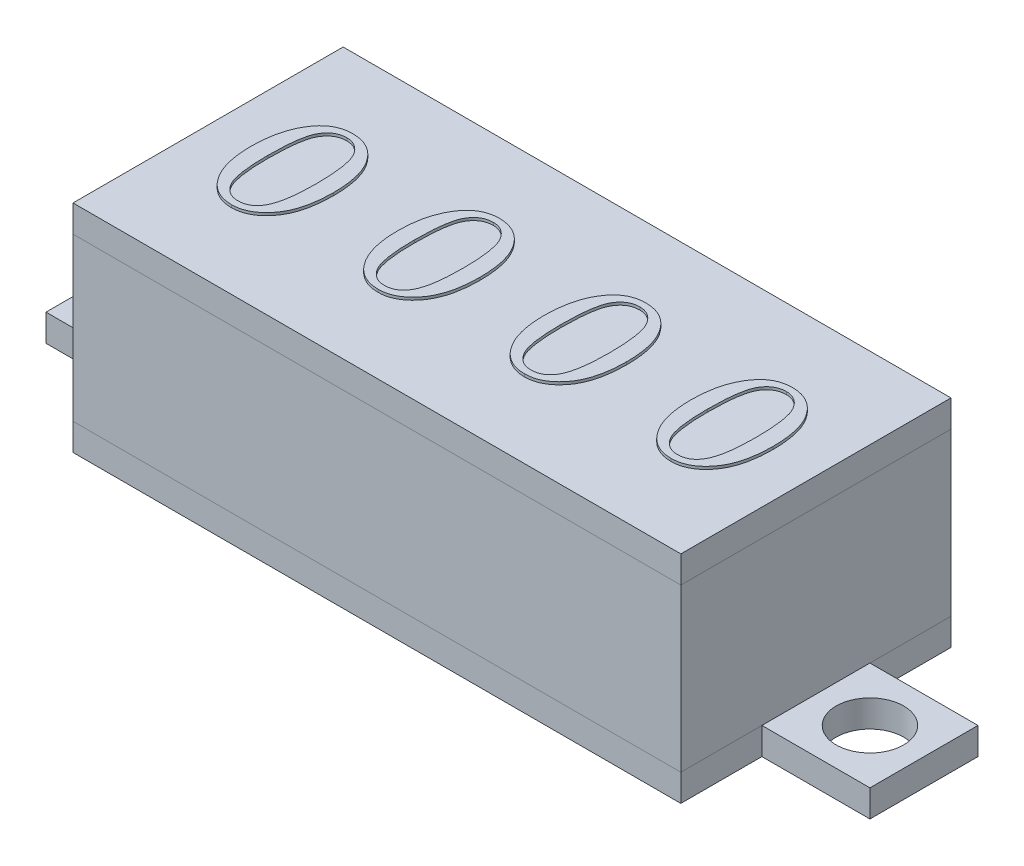
from build123d import *

# Parameters (mm, degrees)
SKETCH1_W           = 22.5
SKETCH1_H           = 10
BOSS_EXTRUDE1_DEPTH = 6
SKETCH2_W           = 4
SKETCH2_H           = 4
SKETCH2_R           = 1.25
BOSS_EXTRUDE2_DEPTH = 1
SKETCH3_W           = 22.5
SKETCH3_H           = 10
BOSS_EXTRUDE3_DEPTH = 1
BOSS_EXTRUDE4_DEPTH = 0.1


with BuildPart() as part:
    # Sketch1 → Boss-Extrude1 (new body)
    with BuildSketch(Plane(origin=(0, 0, 0), x_dir=(1, 0, 0), z_dir=(0, 1, 0))):
        with Locations((-1.188679245, -0.266509434)):
            Rectangle(SKETCH1_W, SKETCH1_H)
    extrude(amount=BOSS_EXTRUDE1_DEPTH)


with BuildPart() as body_2:
    # Sketch2 → Boss-Extrude2 (new body)
    with BuildSketch(Plane.XZ):
        with Locations((12.061320755, 0.266509434)):
            Rectangle(SKETCH2_W, SKETCH2_H)
        with Locations(Location((12.061320755, 0.266509434, 0), (0, 0, 270))):
            Circle(SKETCH2_R, mode=Mode.SUBTRACT)
        Polygon((10.061320755, -4.733490566), (10.061320755, -1.733490566), (10.061320755, 2.266509434), (10.061320755, 5.266509434), (-12.438679245, 5.266509434), (-12.438679245, 2.266509434), (-12.438679245, -1.733490566), (-12.438679245, -4.733490566), align=None)
        with Locations((-14.438679245, 0.266509434)):
            Rectangle(SKETCH2_W, SKETCH2_H)
        with Locations(Location((-14.438679245, 0.266509434, 0), (0, 0, 270))):
            Circle(SKETCH2_R, mode=Mode.SUBTRACT)
    extrude(amount=BOSS_EXTRUDE2_DEPTH)


with BuildPart() as body_3:
    # Sketch3 → Boss-Extrude3 (new body)
    with BuildSketch(Plane(origin=(0, 6, 0), x_dir=(1, 0, 0), z_dir=(0, 1, 0))):
        with Locations((-1.188679245, -0.266509434)):
            Rectangle(SKETCH3_W, SKETCH3_H)
    extrude(amount=BOSS_EXTRUDE3_DEPTH)

    # Sketch4 → Boss-Extrude4 (add)
    with BuildSketch(Plane(origin=(0, 7, 0), x_dir=(1, 0, 0), z_dir=(0, 1, 0))):
        with BuildLine():
            add(Edge.make_bspline(
                [(-9.378258698, 2.032453757), (-9.327945007, 2.031101968), (-9.229301532, 2.028451693), (-9.084815478, 2.004728092), (-8.946425082, 1.968218888), (-8.813834187, 1.916701397), (-8.68887389, 1.847557967), (-8.569923985, 1.765331996), (-8.456275891, 1.669006282), (-8.389049773, 1.594190798), (-8.354734907, 1.55600202)],
                knots=[0, 0, 0, 0, 1.034177873, 2.027577328, 3.003134204, 3.974152387, 4.944805699, 5.933263622, 6.945056114, 8, 8, 8, 8], degree=3))
            add(Edge.make_bspline(
                [(-8.354734907, 1.55600202), (-8.31382028, 1.504857392), (-8.230581065, 1.40080564), (-8.128996208, 1.223059152), (-8.041009839, 1.028343426), (-7.969553671, 0.814433883), (-7.915780217, 0.581591428), (-7.876785917, 0.330148682), (-7.851632366, 0.059989201), (-7.849335115, -0.126586195), (-7.848151835, -0.222688358)],
                knots=[0, 0, 0, 0, 0.831632311, 1.691923517, 2.593854152, 3.545333385, 4.553909998, 5.628531033, 6.778492226, 8, 8, 8, 8], degree=3))
            add(Edge.make_bspline(
                [(-7.848151835, -0.222688358), (-7.849281629, -0.312180841), (-7.851477079, -0.486085272), (-7.872280309, -0.738661839), (-7.907021998, -0.974838883), (-7.954219207, -1.194831114), (-8.016412963, -1.397973632), (-8.091596141, -1.584904206), (-8.181128101, -1.755560206), (-8.284646026, -1.908656843), (-8.397833845, -2.04408024), (-8.51632107, -2.162838309), (-8.641470291, -2.262607987), (-8.77258132, -2.344468194), (-8.909241921, -2.40900764), (-9.052245817, -2.454829643), (-9.200872568, -2.48142185), (-9.301884876, -2.485293605), (-9.352835384, -2.487246514)],
                knots=[0, 0, 0, 0, 1.417208335, 2.753960989, 4.010288699, 5.195991505, 6.314016688, 7.371005355, 8.382792458, 9.360343293, 10.29216761, 11.174475273, 12.012952715, 12.821282545, 13.617429245, 14.400351687, 15.193138972, 16, 16, 16, 16], degree=3))
            add(Edge.make_bspline(
                [(-9.352835384, -2.487246514), (-9.401881597, -2.485821311), (-9.498624784, -2.483010112), (-9.640942977, -2.460001664), (-9.776577486, -2.421166139), (-9.906522268, -2.368241133), (-10.029049142, -2.298465193), (-10.146791862, -2.215418), (-10.257586621, -2.116028725), (-10.323778839, -2.040094149), (-10.35752709, -2.001378735)],
                knots=[0, 0, 0, 0, 1.018622209, 2.009222595, 2.98557584, 3.944681745, 4.91693228, 5.908476626, 6.933632133, 8, 8, 8, 8], degree=3))
            add(Edge.make_bspline(
                [(-10.35752709, -2.001378735), (-10.39796482, -1.948216389), (-10.479896704, -1.840502847), (-10.582423359, -1.660437026), (-10.668839329, -1.464002828), (-10.739375338, -1.250422993), (-10.794616758, -1.020502787), (-10.833713316, -0.773375625), (-10.857456672, -0.509719198), (-10.859985804, -0.328199513), (-10.861285349, -0.234929212)],
                knots=[0, 0, 0, 0, 0.855190123, 1.732721847, 2.647494282, 3.601413261, 4.611082414, 5.674349109, 6.80501028, 8, 8, 8, 8], degree=3))
            add(Edge.make_bspline(
                [(-10.861285349, -0.234929212), (-10.859939267, -0.145737439), (-10.857313641, 0.028237215), (-10.8340092, 0.281995331), (-10.797941251, 0.522150879), (-10.746589341, 0.748339982), (-10.679506042, 0.960640075), (-10.597867472, 1.158754173), (-10.5009474, 1.343149909), (-10.423905088, 1.455929576), (-10.385775216, 1.511746621)],
                knots=[0, 0, 0, 0, 1.162878212, 2.268273489, 3.320083559, 4.327872371, 5.289661935, 6.220038334, 7.119059284, 8, 8, 8, 8], degree=3))
            add(Edge.make_bspline(
                [(-10.385775216, 1.511746621), (-10.353813844, 1.553413836), (-10.291286426, 1.634929216), (-10.182539121, 1.740208345), (-10.068021145, 1.831225702), (-9.944962882, 1.905145925), (-9.813761343, 1.961986842), (-9.675236229, 2.002454193), (-9.529199509, 2.027634542), (-9.429207704, 2.030827065), (-9.378258698, 2.032453757)],
                knots=[0, 0, 0, 0, 1.066527708, 2.08649442, 3.068328227, 4.035911514, 4.996311456, 5.967697152, 6.964477018, 8, 8, 8, 8], degree=3))
        make_face()
        with BuildLine():
            add(Edge.make_bspline(
                [(-9.362251426, 1.791403075), (-9.396529152, 1.790011067), (-9.463676528, 1.787284233), (-9.561853206, 1.769545387), (-9.653624387, 1.737682746), (-9.740621892, 1.695685807), (-9.820200767, 1.638511613), (-9.895103183, 1.570785024), (-9.962847507, 1.489436499), (-10.026828298, 1.395476833), (-10.083427544, 1.281246514), (-10.130418486, 1.142150051), (-10.17000084, 0.977225299), (-10.202054053, 0.786168713), (-10.228576699, 0.56943137), (-10.245112605, 0.32615728), (-10.256875712, 0.056769956), (-10.258046281, -0.131651492), (-10.258658646, -0.230221191)],
                knots=[0, 0, 0, 0, 0.667148774, 1.30689213, 1.932721232, 2.552800968, 3.179791468, 3.832667273, 4.513077547, 5.234758394, 6.04058107, 6.985198211, 8.085901752, 9.338111265, 10.75333435, 12.333478328, 14.081917187, 16, 16, 16, 16], degree=3))
            add(Edge.make_bspline(
                [(-10.258658646, -0.230221191), (-10.257958801, -0.326586914), (-10.256617852, -0.511229992), (-10.245925051, -0.775737788), (-10.225871565, -1.014995372), (-10.200833721, -1.229576412), (-10.16589439, -1.418750484), (-10.125859893, -1.583654584), (-10.07641727, -1.723383545), (-10.018403741, -1.839948095), (-9.95269732, -1.936290582), (-9.884136959, -2.019558757), (-9.808609872, -2.088903785), (-9.728742414, -2.146921369), (-9.643125643, -2.19181073), (-9.552300578, -2.222986474), (-9.456293528, -2.242428337), (-9.390279148, -2.244923117), (-9.3566018, -2.246195833)],
                knots=[0, 0, 0, 0, 1.884102424, 3.610064464, 5.174084282, 6.577654309, 7.831839042, 8.933221405, 9.89214569, 10.723697405, 11.470879788, 12.167811872, 12.827890927, 13.469923399, 14.092994405, 14.710144424, 15.341977984, 16, 16, 16, 16], degree=3))
            add(Edge.make_bspline(
                [(-9.3566018, -2.246195833), (-9.32292856, -2.245253699), (-9.256963501, -2.243408083), (-9.161117903, -2.224692504), (-9.071063216, -2.1957724), (-8.9869214, -2.15473025), (-8.909343422, -2.101600569), (-8.838328527, -2.036521993), (-8.772356363, -1.960677737), (-8.735370795, -1.903028888), (-8.716310929, -1.87332056)],
                knots=[0, 0, 0, 0, 1.037540769, 2.032517106, 2.999982528, 3.948219519, 4.909561987, 5.889684619, 6.91248581, 8, 8, 8, 8], degree=3))
            add(Edge.make_bspline(
                [(-8.716310929, -1.87332056), (-8.694577417, -1.832982896), (-8.648365149, -1.74721236), (-8.596566318, -1.600008061), (-8.550607716, -1.431387215), (-8.513377116, -1.239704893), (-8.48607819, -1.02513749), (-8.465882729, -0.787956682), (-8.452158803, -0.52761392), (-8.451251549, -0.346371551), (-8.450778538, -0.251878088)],
                knots=[0, 0, 0, 0, 0.662021917, 1.407666401, 2.250371803, 3.189876895, 4.229599255, 5.378231133, 6.633100965, 8, 8, 8, 8], degree=3))
            add(Edge.make_bspline(
                [(-8.450778538, -0.251878088), (-8.451302093, -0.154561109), (-8.452304066, 0.031683138), (-8.465277516, 0.298561732), (-8.48286837, 0.540236041), (-8.509624526, 0.756914524), (-8.545521026, 0.948250324), (-8.586226799, 1.115429661), (-8.636785672, 1.257308046), (-8.695764485, 1.375703343), (-8.762318342, 1.474020603), (-8.832257707, 1.558975759), (-8.907352014, 1.631088409), (-8.988673696, 1.689468841), (-9.074945627, 1.734832614), (-9.165901432, 1.768544039), (-9.262599914, 1.78751693), (-9.328587663, 1.790090278), (-9.362251426, 1.791403075)],
                knots=[0, 0, 0, 0, 1.880898734, 3.599644876, 5.163555013, 6.563973479, 7.81694835, 8.92495287, 9.886457661, 10.722129126, 11.474279202, 12.176496217, 12.845948905, 13.480688063, 14.104872593, 14.724796833, 15.349452935, 16, 16, 16, 16], degree=3))
        make_face(mode=Mode.SUBTRACT)
        with BuildLine():
            add(Edge.make_bspline(
                [(-3.954618373, 2.032453757), (-3.904304682, 2.031101968), (-3.805661208, 2.028451693), (-3.661175153, 2.004728092), (-3.522784757, 1.968218888), (-3.390193862, 1.916701397), (-3.265233565, 1.847557967), (-3.14628366, 1.765331996), (-3.032635566, 1.669006282), (-2.965409449, 1.594190798), (-2.931094583, 1.55600202)],
                knots=[0, 0, 0, 0, 1.034177873, 2.027577328, 3.003134204, 3.974152387, 4.944805699, 5.933263622, 6.945056114, 8, 8, 8, 8], degree=3))
            add(Edge.make_bspline(
                [(-2.931094583, 1.55600202), (-2.890179955, 1.504857392), (-2.80694074, 1.40080564), (-2.705355884, 1.223059152), (-2.617369514, 1.028343426), (-2.545913346, 0.814433883), (-2.492139892, 0.581591428), (-2.453145593, 0.330148682), (-2.427992042, 0.059989201), (-2.42569479, -0.126586195), (-2.424511511, -0.222688358)],
                knots=[0, 0, 0, 0, 0.831632311, 1.691923517, 2.593854152, 3.545333385, 4.553909998, 5.628531033, 6.778492226, 8, 8, 8, 8], degree=3))
            add(Edge.make_bspline(
                [(-2.424511511, -0.222688358), (-2.425641305, -0.312180841), (-2.427836754, -0.486085272), (-2.448639984, -0.738661839), (-2.483381673, -0.974838883), (-2.530578882, -1.194831114), (-2.592772638, -1.397973632), (-2.667955816, -1.584904206), (-2.757487776, -1.755560206), (-2.861005701, -1.908656843), (-2.974193521, -2.04408024), (-3.092680746, -2.162838309), (-3.217829967, -2.262607987), (-3.348940996, -2.344468194), (-3.485601596, -2.40900764), (-3.628605493, -2.454829643), (-3.777232244, -2.48142185), (-3.878244551, -2.485293605), (-3.929195059, -2.487246514)],
                knots=[0, 0, 0, 0, 1.417208335, 2.753960989, 4.010288699, 5.195991505, 6.314016688, 7.371005355, 8.382792458, 9.360343293, 10.29216761, 11.174475273, 12.012952715, 12.821282545, 13.617429245, 14.400351687, 15.193138972, 16, 16, 16, 16], degree=3))
            add(Edge.make_bspline(
                [(-3.929195059, -2.487246514), (-3.978241272, -2.485821311), (-4.07498446, -2.483010112), (-4.217302653, -2.460001664), (-4.352937161, -2.421166139), (-4.482881943, -2.368241133), (-4.605408817, -2.298465193), (-4.723151537, -2.215418), (-4.833946296, -2.116028725), (-4.900138515, -2.040094149), (-4.933886765, -2.001378735)],
                knots=[0, 0, 0, 0, 1.018622209, 2.009222595, 2.98557584, 3.944681745, 4.91693228, 5.908476626, 6.933632133, 8, 8, 8, 8], degree=3))
            add(Edge.make_bspline(
                [(-4.933886765, -2.001378735), (-4.974324495, -1.948216389), (-5.05625638, -1.840502847), (-5.158783035, -1.660437026), (-5.245199005, -1.464002828), (-5.315735013, -1.250422993), (-5.370976434, -1.020502787), (-5.410072992, -0.773375625), (-5.433816348, -0.509719198), (-5.43634548, -0.328199513), (-5.437645024, -0.234929212)],
                knots=[0, 0, 0, 0, 0.855190123, 1.732721847, 2.647494282, 3.601413261, 4.611082414, 5.674349109, 6.80501028, 8, 8, 8, 8], degree=3))
            add(Edge.make_bspline(
                [(-5.437645024, -0.234929212), (-5.436298942, -0.145737439), (-5.433673317, 0.028237215), (-5.410368876, 0.281995331), (-5.374300926, 0.522150879), (-5.322949016, 0.748339982), (-5.255865718, 0.960640075), (-5.174227148, 1.158754173), (-5.077307075, 1.343149909), (-5.000264763, 1.455929576), (-4.962134892, 1.511746621)],
                knots=[0, 0, 0, 0, 1.162878212, 2.268273489, 3.320083559, 4.327872371, 5.289661935, 6.220038334, 7.119059284, 8, 8, 8, 8], degree=3))
            add(Edge.make_bspline(
                [(-4.962134892, 1.511746621), (-4.93017352, 1.553413836), (-4.867646101, 1.634929216), (-4.758898797, 1.740208345), (-4.644380821, 1.831225702), (-4.521322557, 1.905145925), (-4.390121019, 1.961986842), (-4.251595904, 2.002454193), (-4.105559185, 2.027634542), (-4.00556738, 2.030827065), (-3.954618373, 2.032453757)],
                knots=[0, 0, 0, 0, 1.066527708, 2.08649442, 3.068328227, 4.035911514, 4.996311456, 5.967697152, 6.964477018, 8, 8, 8, 8], degree=3))
        make_face()
        with BuildLine():
            add(Edge.make_bspline(
                [(-3.938611101, 1.791403075), (-3.972888827, 1.790011067), (-4.040036204, 1.787284233), (-4.138212882, 1.769545387), (-4.229984062, 1.737682746), (-4.316981567, 1.695685807), (-4.396560442, 1.638511613), (-4.471462859, 1.570785024), (-4.539207183, 1.489436499), (-4.603187974, 1.395476833), (-4.65978722, 1.281246514), (-4.706778162, 1.142150051), (-4.746360515, 0.977225299), (-4.778413728, 0.786168713), (-4.804936374, 0.56943137), (-4.82147228, 0.32615728), (-4.833235388, 0.056769956), (-4.834405957, -0.131651492), (-4.835018322, -0.230221191)],
                knots=[0, 0, 0, 0, 0.667148774, 1.30689213, 1.932721232, 2.552800968, 3.179791468, 3.832667273, 4.513077547, 5.234758394, 6.04058107, 6.985198211, 8.085901752, 9.338111265, 10.75333435, 12.333478328, 14.081917187, 16, 16, 16, 16], degree=3))
            add(Edge.make_bspline(
                [(-4.835018322, -0.230221191), (-4.834318476, -0.326586914), (-4.832977527, -0.511229992), (-4.822284726, -0.775737788), (-4.80223124, -1.014995372), (-4.777193396, -1.229576412), (-4.742254066, -1.418750484), (-4.702219569, -1.583654584), (-4.652776946, -1.723383545), (-4.594763416, -1.839948095), (-4.529056995, -1.936290582), (-4.460496635, -2.019558757), (-4.384969547, -2.088903785), (-4.305102089, -2.146921369), (-4.219485318, -2.19181073), (-4.128660254, -2.222986474), (-4.032653204, -2.242428337), (-3.966638824, -2.244923117), (-3.932961476, -2.246195833)],
                knots=[0, 0, 0, 0, 1.884102424, 3.610064464, 5.174084282, 6.577654309, 7.831839042, 8.933221405, 9.89214569, 10.723697405, 11.470879788, 12.167811872, 12.827890927, 13.469923399, 14.092994405, 14.710144424, 15.341977984, 16, 16, 16, 16], degree=3))
            add(Edge.make_bspline(
                [(-3.932961476, -2.246195833), (-3.899288235, -2.245253699), (-3.833323177, -2.243408083), (-3.737477578, -2.224692504), (-3.647422892, -2.1957724), (-3.563281076, -2.15473025), (-3.485703097, -2.101600569), (-3.414688202, -2.036521993), (-3.348716038, -1.960677737), (-3.311730471, -1.903028888), (-3.292670604, -1.87332056)],
                knots=[0, 0, 0, 0, 1.037540769, 2.032517106, 2.999982528, 3.948219519, 4.909561987, 5.889684619, 6.91248581, 8, 8, 8, 8], degree=3))
            add(Edge.make_bspline(
                [(-3.292670604, -1.87332056), (-3.270937093, -1.832982896), (-3.224724825, -1.74721236), (-3.172925993, -1.600008061), (-3.126967392, -1.431387215), (-3.089736791, -1.239704893), (-3.062437865, -1.02513749), (-3.042242404, -0.787956682), (-3.028518478, -0.52761392), (-3.027611224, -0.346371551), (-3.027138213, -0.251878088)],
                knots=[0, 0, 0, 0, 0.662021917, 1.407666401, 2.250371803, 3.189876895, 4.229599255, 5.378231133, 6.633100965, 8, 8, 8, 8], degree=3))
            add(Edge.make_bspline(
                [(-3.027138213, -0.251878088), (-3.027661768, -0.154561109), (-3.028663741, 0.031683138), (-3.041637191, 0.298561732), (-3.059228046, 0.540236041), (-3.085984201, 0.756914524), (-3.121880702, 0.948250324), (-3.162586475, 1.115429661), (-3.213145348, 1.257308046), (-3.272124161, 1.375703343), (-3.338678017, 1.474020603), (-3.408617382, 1.558975759), (-3.48371169, 1.631088409), (-3.565033371, 1.689468841), (-3.651305303, 1.734832614), (-3.742261108, 1.768544039), (-3.83895959, 1.78751693), (-3.904947339, 1.790090278), (-3.938611101, 1.791403075)],
                knots=[0, 0, 0, 0, 1.880898734, 3.599644876, 5.163555013, 6.563973479, 7.81694835, 8.92495287, 9.886457661, 10.722129126, 11.474279202, 12.176496217, 12.845948905, 13.480688063, 14.104872593, 14.724796833, 15.349452935, 16, 16, 16, 16], degree=3))
        make_face(mode=Mode.SUBTRACT)
        with BuildLine():
            add(Edge.make_bspline(
                [(1.469021951, 2.032453757), (1.519335642, 2.031101968), (1.617979117, 2.028451693), (1.762465171, 2.004728092), (1.900855568, 1.968218888), (2.033446462, 1.916701397), (2.158406759, 1.847557967), (2.277356664, 1.765331996), (2.391004758, 1.669006282), (2.458230876, 1.594190798), (2.492545742, 1.55600202)],
                knots=[0, 0, 0, 0, 1.034177873, 2.027577328, 3.003134204, 3.974152387, 4.944805699, 5.933263622, 6.945056114, 8, 8, 8, 8], degree=3))
            add(Edge.make_bspline(
                [(2.492545742, 1.55600202), (2.533460369, 1.504857392), (2.616699584, 1.40080564), (2.718284441, 1.223059152), (2.80627081, 1.028343426), (2.877726978, 0.814433883), (2.931500432, 0.581591428), (2.970494732, 0.330148682), (2.995648283, 0.059989201), (2.997945534, -0.126586195), (2.999128814, -0.222688358)],
                knots=[0, 0, 0, 0, 0.831632311, 1.691923517, 2.593854152, 3.545333385, 4.553909998, 5.628531033, 6.778492226, 8, 8, 8, 8], degree=3))
            add(Edge.make_bspline(
                [(2.999128814, -0.222688358), (2.99799902, -0.312180841), (2.99580357, -0.486085272), (2.97500034, -0.738661839), (2.940258651, -0.974838883), (2.893061442, -1.194831114), (2.830867686, -1.397973632), (2.755684508, -1.584904206), (2.666152548, -1.755560206), (2.562634623, -1.908656843), (2.449446804, -2.04408024), (2.330959579, -2.162838309), (2.205810358, -2.262607987), (2.074699329, -2.344468194), (1.938038728, -2.40900764), (1.795034832, -2.454829643), (1.646408081, -2.48142185), (1.545395774, -2.485293605), (1.494445265, -2.487246514)],
                knots=[0, 0, 0, 0, 1.417208335, 2.753960989, 4.010288699, 5.195991505, 6.314016688, 7.371005355, 8.382792458, 9.360343293, 10.29216761, 11.174475273, 12.012952715, 12.821282545, 13.617429245, 14.400351687, 15.193138972, 16, 16, 16, 16], degree=3))
            add(Edge.make_bspline(
                [(1.494445265, -2.487246514), (1.445399052, -2.485821311), (1.348655865, -2.483010112), (1.206337672, -2.460001664), (1.070703163, -2.421166139), (0.940758381, -2.368241133), (0.818231507, -2.298465193), (0.700488787, -2.215418), (0.589694028, -2.116028725), (0.52350181, -2.040094149), (0.48975356, -2.001378735)],
                knots=[0, 0, 0, 0, 1.018622209, 2.009222595, 2.98557584, 3.944681745, 4.91693228, 5.908476626, 6.933632133, 8, 8, 8, 8], degree=3))
            add(Edge.make_bspline(
                [(0.48975356, -2.001378735), (0.449315829, -1.948216389), (0.367383945, -1.840502847), (0.26485729, -1.660437026), (0.17844132, -1.464002828), (0.107905311, -1.250422993), (0.052663891, -1.020502787), (0.013567333, -0.773375625), (-0.010176023, -0.509719198), (-0.012705155, -0.328199513), (-0.0140047, -0.234929212)],
                knots=[0, 0, 0, 0, 0.855190123, 1.732721847, 2.647494282, 3.601413261, 4.611082414, 5.674349109, 6.80501028, 8, 8, 8, 8], degree=3))
            add(Edge.make_bspline(
                [(-0.0140047, -0.234929212), (-0.012658618, -0.145737439), (-0.010032992, 0.028237215), (0.013271449, 0.281995331), (0.049339399, 0.522150879), (0.100691308, 0.748339982), (0.167774607, 0.960640075), (0.249413177, 1.158754173), (0.346333249, 1.343149909), (0.423375561, 1.455929576), (0.461505433, 1.511746621)],
                knots=[0, 0, 0, 0, 1.162878212, 2.268273489, 3.320083559, 4.327872371, 5.289661935, 6.220038334, 7.119059284, 8, 8, 8, 8], degree=3))
            add(Edge.make_bspline(
                [(0.461505433, 1.511746621), (0.493466805, 1.553413836), (0.555994223, 1.634929216), (0.664741528, 1.740208345), (0.779259504, 1.831225702), (0.902317767, 1.905145925), (1.033519306, 1.961986842), (1.17204442, 2.002454193), (1.31808114, 2.027634542), (1.418072945, 2.030827065), (1.469021951, 2.032453757)],
                knots=[0, 0, 0, 0, 1.066527708, 2.08649442, 3.068328227, 4.035911514, 4.996311456, 5.967697152, 6.964477018, 8, 8, 8, 8], degree=3))
        make_face()
        with BuildLine():
            add(Edge.make_bspline(
                [(1.485029223, 1.791403075), (1.450751497, 1.790011067), (1.383604121, 1.787284233), (1.285427443, 1.769545387), (1.193656262, 1.737682746), (1.106658757, 1.695685807), (1.027079882, 1.638511613), (0.952177466, 1.570785024), (0.884433142, 1.489436499), (0.820452351, 1.395476833), (0.763853105, 1.281246514), (0.716862163, 1.142150051), (0.677279809, 0.977225299), (0.645226597, 0.786168713), (0.61870395, 0.56943137), (0.602168044, 0.32615728), (0.590404937, 0.056769956), (0.589234368, -0.131651492), (0.588622003, -0.230221191)],
                knots=[0, 0, 0, 0, 0.667148774, 1.30689213, 1.932721232, 2.552800968, 3.179791468, 3.832667273, 4.513077547, 5.234758394, 6.04058107, 6.985198211, 8.085901752, 9.338111265, 10.75333435, 12.333478328, 14.081917187, 16, 16, 16, 16], degree=3))
            add(Edge.make_bspline(
                [(0.588622003, -0.230221191), (0.589321848, -0.326586914), (0.590662797, -0.511229992), (0.601355598, -0.775737788), (0.621409084, -1.014995372), (0.646446928, -1.229576412), (0.681386259, -1.418750484), (0.721420756, -1.583654584), (0.770863379, -1.723383545), (0.828876908, -1.839948095), (0.894583329, -1.936290582), (0.96314369, -2.019558757), (1.038670777, -2.088903785), (1.118538235, -2.146921369), (1.204155006, -2.19181073), (1.294980071, -2.222986474), (1.390987121, -2.242428337), (1.457001501, -2.244923117), (1.490678849, -2.246195833)],
                knots=[0, 0, 0, 0, 1.884102424, 3.610064464, 5.174084282, 6.577654309, 7.831839042, 8.933221405, 9.89214569, 10.723697405, 11.470879788, 12.167811872, 12.827890927, 13.469923399, 14.092994405, 14.710144424, 15.341977984, 16, 16, 16, 16], degree=3))
            add(Edge.make_bspline(
                [(1.490678849, -2.246195833), (1.524352089, -2.245253699), (1.590317148, -2.243408083), (1.686162746, -2.224692504), (1.776217433, -2.1957724), (1.860359249, -2.15473025), (1.937937228, -2.101600569), (2.008952122, -2.036521993), (2.074924286, -1.960677737), (2.111909854, -1.903028888), (2.13096972, -1.87332056)],
                knots=[0, 0, 0, 0, 1.037540769, 2.032517106, 2.999982528, 3.948219519, 4.909561987, 5.889684619, 6.91248581, 8, 8, 8, 8], degree=3))
            add(Edge.make_bspline(
                [(2.13096972, -1.87332056), (2.152703232, -1.832982896), (2.1989155, -1.74721236), (2.250714331, -1.600008061), (2.296672933, -1.431387215), (2.333903533, -1.239704893), (2.361202459, -1.02513749), (2.38139792, -0.787956682), (2.395121846, -0.52761392), (2.3960291, -0.346371551), (2.396502111, -0.251878088)],
                knots=[0, 0, 0, 0, 0.662021917, 1.407666401, 2.250371803, 3.189876895, 4.229599255, 5.378231133, 6.633100965, 8, 8, 8, 8], degree=3))
            add(Edge.make_bspline(
                [(2.396502111, -0.251878088), (2.395978557, -0.154561109), (2.394976583, 0.031683138), (2.382003133, 0.298561732), (2.364412279, 0.540236041), (2.337656123, 0.756914524), (2.301759623, 0.948250324), (2.26105385, 1.115429661), (2.210494977, 1.257308046), (2.151516164, 1.375703343), (2.084962307, 1.474020603), (2.015022942, 1.558975759), (1.939928635, 1.631088409), (1.858606953, 1.689468841), (1.772335022, 1.734832614), (1.681379217, 1.768544039), (1.584680735, 1.78751693), (1.518692986, 1.790090278), (1.485029223, 1.791403075)],
                knots=[0, 0, 0, 0, 1.880898734, 3.599644876, 5.163555013, 6.563973479, 7.81694835, 8.92495287, 9.886457661, 10.722129126, 11.474279202, 12.176496217, 12.845948905, 13.480688063, 14.104872593, 14.724796833, 15.349452935, 16, 16, 16, 16], degree=3))
        make_face(mode=Mode.SUBTRACT)
        with BuildLine():
            add(Edge.make_bspline(
                [(6.892662276, 2.032453757), (6.942975967, 2.031101968), (7.041619441, 2.028451693), (7.186105496, 2.004728092), (7.324495892, 1.968218888), (7.457086787, 1.916701397), (7.582047084, 1.847557967), (7.700996989, 1.765331996), (7.814645083, 1.669006282), (7.881871201, 1.594190798), (7.916186066, 1.55600202)],
                knots=[0, 0, 0, 0, 1.034177873, 2.027577328, 3.003134204, 3.974152387, 4.944805699, 5.933263622, 6.945056114, 8, 8, 8, 8], degree=3))
            add(Edge.make_bspline(
                [(7.916186066, 1.55600202), (7.957100694, 1.504857392), (8.040339909, 1.40080564), (8.141924765, 1.223059152), (8.229911135, 1.028343426), (8.301367303, 0.814433883), (8.355140757, 0.581591428), (8.394135057, 0.330148682), (8.419288607, 0.059989201), (8.421585859, -0.126586195), (8.422769138, -0.222688358)],
                knots=[0, 0, 0, 0, 0.831632311, 1.691923517, 2.593854152, 3.545333385, 4.553909998, 5.628531033, 6.778492226, 8, 8, 8, 8], degree=3))
            add(Edge.make_bspline(
                [(8.422769138, -0.222688358), (8.421639344, -0.312180841), (8.419443895, -0.486085272), (8.398640665, -0.738661839), (8.363898976, -0.974838883), (8.316701767, -1.194831114), (8.254508011, -1.397973632), (8.179324833, -1.584904206), (8.089792873, -1.755560206), (7.986274948, -1.908656843), (7.873087128, -2.04408024), (7.754599903, -2.162838309), (7.629450682, -2.262607987), (7.498339654, -2.344468194), (7.361679053, -2.40900764), (7.218675156, -2.454829643), (7.070048405, -2.48142185), (6.969036098, -2.485293605), (6.91808559, -2.487246514)],
                knots=[0, 0, 0, 0, 1.417208335, 2.753960989, 4.010288699, 5.195991505, 6.314016688, 7.371005355, 8.382792458, 9.360343293, 10.29216761, 11.174475273, 12.012952715, 12.821282545, 13.617429245, 14.400351687, 15.193138972, 16, 16, 16, 16], degree=3))
            add(Edge.make_bspline(
                [(6.91808559, -2.487246514), (6.869039377, -2.485821311), (6.772296189, -2.483010112), (6.629977996, -2.460001664), (6.494343488, -2.421166139), (6.364398706, -2.368241133), (6.241871832, -2.298465193), (6.124129112, -2.215418), (6.013334353, -2.116028725), (5.947142135, -2.040094149), (5.913393884, -2.001378735)],
                knots=[0, 0, 0, 0, 1.018622209, 2.009222595, 2.98557584, 3.944681745, 4.91693228, 5.908476626, 6.933632133, 8, 8, 8, 8], degree=3))
            add(Edge.make_bspline(
                [(5.913393884, -2.001378735), (5.872956154, -1.948216389), (5.791024269, -1.840502847), (5.688497615, -1.660437026), (5.602081644, -1.464002828), (5.531545636, -1.250422993), (5.476304215, -1.020502787), (5.437207657, -0.773375625), (5.413464301, -0.509719198), (5.410935169, -0.328199513), (5.409635625, -0.234929212)],
                knots=[0, 0, 0, 0, 0.855190123, 1.732721847, 2.647494282, 3.601413261, 4.611082414, 5.674349109, 6.80501028, 8, 8, 8, 8], degree=3))
            add(Edge.make_bspline(
                [(5.409635625, -0.234929212), (5.410981707, -0.145737439), (5.413607332, 0.028237215), (5.436911773, 0.281995331), (5.472979723, 0.522150879), (5.524331633, 0.748339982), (5.591414931, 0.960640075), (5.673053501, 1.158754173), (5.769973574, 1.343149909), (5.847015886, 1.455929576), (5.885145757, 1.511746621)],
                knots=[0, 0, 0, 0, 1.162878212, 2.268273489, 3.320083559, 4.327872371, 5.289661935, 6.220038334, 7.119059284, 8, 8, 8, 8], degree=3))
            add(Edge.make_bspline(
                [(5.885145757, 1.511746621), (5.917107129, 1.553413836), (5.979634548, 1.634929216), (6.088381852, 1.740208345), (6.202899828, 1.831225702), (6.325958092, 1.905145925), (6.45715963, 1.961986842), (6.595684745, 2.002454193), (6.741721464, 2.027634542), (6.841713269, 2.030827065), (6.892662276, 2.032453757)],
                knots=[0, 0, 0, 0, 1.066527708, 2.08649442, 3.068328227, 4.035911514, 4.996311456, 5.967697152, 6.964477018, 8, 8, 8, 8], degree=3))
        make_face()
        with BuildLine():
            add(Edge.make_bspline(
                [(6.908669548, 1.791403075), (6.874391822, 1.790011067), (6.807244445, 1.787284233), (6.709067767, 1.769545387), (6.617296587, 1.737682746), (6.530299082, 1.695685807), (6.450720207, 1.638511613), (6.37581779, 1.570785024), (6.308073466, 1.489436499), (6.244092675, 1.395476833), (6.187493429, 1.281246514), (6.140502487, 1.142150051), (6.100920134, 0.977225299), (6.068866921, 0.786168713), (6.042344275, 0.56943137), (6.025808369, 0.32615728), (6.014045261, 0.056769956), (6.012874692, -0.131651492), (6.012262327, -0.230221191)],
                knots=[0, 0, 0, 0, 0.667148774, 1.30689213, 1.932721232, 2.552800968, 3.179791468, 3.832667273, 4.513077547, 5.234758394, 6.04058107, 6.985198211, 8.085901752, 9.338111265, 10.75333435, 12.333478328, 14.081917187, 16, 16, 16, 16], degree=3))
            add(Edge.make_bspline(
                [(6.012262327, -0.230221191), (6.012962173, -0.326586914), (6.014303122, -0.511229992), (6.024995923, -0.775737788), (6.045049409, -1.014995372), (6.070087253, -1.229576412), (6.105026583, -1.418750484), (6.14506108, -1.583654584), (6.194503703, -1.723383545), (6.252517233, -1.839948095), (6.318223654, -1.936290582), (6.386784014, -2.019558757), (6.462311102, -2.088903785), (6.54217856, -2.146921369), (6.627795331, -2.19181073), (6.718620395, -2.222986474), (6.814627445, -2.242428337), (6.880641825, -2.244923117), (6.914319173, -2.246195833)],
                knots=[0, 0, 0, 0, 1.884102424, 3.610064464, 5.174084282, 6.577654309, 7.831839042, 8.933221405, 9.89214569, 10.723697405, 11.470879788, 12.167811872, 12.827890927, 13.469923399, 14.092994405, 14.710144424, 15.341977984, 16, 16, 16, 16], degree=3))
            add(Edge.make_bspline(
                [(6.914319173, -2.246195833), (6.947992414, -2.245253699), (7.013957472, -2.243408083), (7.109803071, -2.224692504), (7.199857757, -2.1957724), (7.283999573, -2.15473025), (7.361577552, -2.101600569), (7.432592447, -2.036521993), (7.498564611, -1.960677737), (7.535550178, -1.903028888), (7.554610045, -1.87332056)],
                knots=[0, 0, 0, 0, 1.037540769, 2.032517106, 2.999982528, 3.948219519, 4.909561987, 5.889684619, 6.91248581, 8, 8, 8, 8], degree=3))
            add(Edge.make_bspline(
                [(7.554610045, -1.87332056), (7.576343556, -1.832982896), (7.622555824, -1.74721236), (7.674354656, -1.600008061), (7.720313257, -1.431387215), (7.757543858, -1.239704893), (7.784842784, -1.02513749), (7.805038245, -0.787956682), (7.818762171, -0.52761392), (7.819669425, -0.346371551), (7.820142436, -0.251878088)],
                knots=[0, 0, 0, 0, 0.662021917, 1.407666401, 2.250371803, 3.189876895, 4.229599255, 5.378231133, 6.633100965, 8, 8, 8, 8], degree=3))
            add(Edge.make_bspline(
                [(7.820142436, -0.251878088), (7.819618881, -0.154561109), (7.818616908, 0.031683138), (7.805643458, 0.298561732), (7.788052603, 0.540236041), (7.761296448, 0.756914524), (7.725399947, 0.948250324), (7.684694174, 1.115429661), (7.634135301, 1.257308046), (7.575156488, 1.375703343), (7.508602632, 1.474020603), (7.438663267, 1.558975759), (7.363568959, 1.631088409), (7.282247278, 1.689468841), (7.195975346, 1.734832614), (7.105019541, 1.768544039), (7.008321059, 1.78751693), (6.94233331, 1.790090278), (6.908669548, 1.791403075)],
                knots=[0, 0, 0, 0, 1.880898734, 3.599644876, 5.163555013, 6.563973479, 7.81694835, 8.92495287, 9.886457661, 10.722129126, 11.474279202, 12.176496217, 12.845948905, 13.480688063, 14.104872593, 14.724796833, 15.349452935, 16, 16, 16, 16], degree=3))
        make_face(mode=Mode.SUBTRACT)
    extrude(amount=BOSS_EXTRUDE4_DEPTH)


solid = Compound([part.part, body_2.part, body_3.part])
